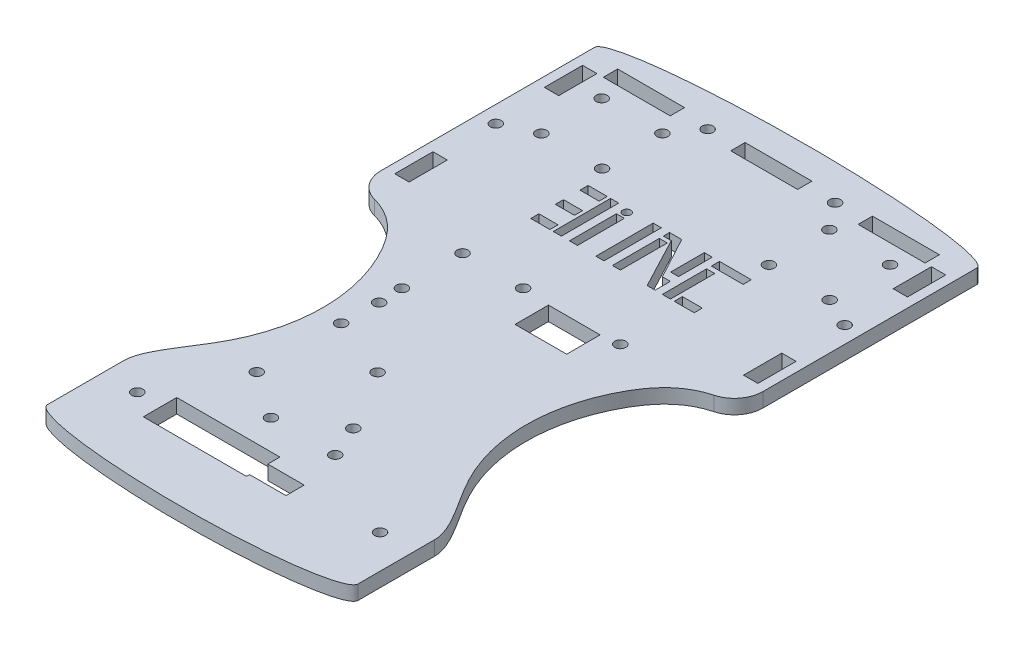
from build123d import *

# Parameters (mm, degrees)
SKETCH1_W           = 80
SKETCH1_H           = 100
BOSS_EXTRUDE1_DEPTH = 1.5
SKETCH2_R           = 1.15
SKETCH2_W           = 14
SKETCH2_H           = 3
CUT_EXTRUDE1_DEPTH  = 4
SKETCH3_R           = 1.15
SKETCH3_W           = 3
SKETCH3_H           = 8
CUT_EXTRUDE2_DEPTH  = 4
BOSS_EXTRUDE2_DEPTH = 3
SKETCH9_W           = 80
SKETCH9_H           = 6
BOSS_EXTRUDE3_DEPTH = 3
CUT_EXTRUDE4_DEPTH  = 4.0000001
BOSS_EXTRUDE4_DEPTH = 3
SKETCH12_R          = 1.143
CUT_EXTRUDE5_DEPTH  = 4.0000001
SKETCH13_R          = 1.15
CUT_EXTRUDE6_DEPTH  = 4.0000001
CUT_EXTRUDE7_DEPTH  = 4.0000001
FILLET1_R           = 6
SKETCH16_R          = 1.15
CUT_EXTRUDE8_DEPTH  = 4.0000001
SKETCH18_R          = 1.15
CUT_EXTRUDE10_DEPTH = 10
SKETCH20_W          = 1.668725188
SKETCH20_H          = 9.826400532
SKETCH20_W_2        = 1.7
SKETCH20_H_2        = 12
SKETCH20_W_3        = 1.668725187
SKETCH20_R          = 0.85
SKETCH20_W_4        = 4
SKETCH20_H_3        = 1.7
SKETCH20_W_5        = 1.660704434
SKETCH20_H_4        = 7.055688022
SKETCH20_H_5        = 9.27636253
SKETCH20_W_6        = 6.651137072
SKETCH20_W_7        = 4.178850885
CUT_EXTRUDE14_DEPTH = 10
SKETCH21_W          = 10.8
SKETCH21_H          = 7
SKETCH21_W_2        = 21.59
SKETCH21_H_2        = 0.65
CUT_EXTRUDE16_DEPTH = 10


with BuildPart() as part:
    # Sketch1 → Boss-Extrude1 (new body, symmetric)
    with BuildSketch(Plane(origin=(0, 0, 0), x_dir=(1, 0, 0), z_dir=(0, 1, 0))):
        Rectangle(SKETCH1_W, SKETCH1_H)
    extrude(amount=BOSS_EXTRUDE1_DEPTH, both=True)

    # Sketch2 → Cut-Extrude1 (cut, through all)
    with BuildSketch(Plane(origin=(0, 1.5, 0), x_dir=(1, 0, 0), z_dir=(0, 1, 0))):
        with Locations((-13.333333333, 47)):
            Circle(SKETCH2_R)
        with Locations((13.333333333, 47)):
            Circle(SKETCH2_R)
        with Locations((-26.666666667, 47)):
            Rectangle(SKETCH2_W, SKETCH2_H)
        with Locations((0, 47)):
            Rectangle(SKETCH2_W, SKETCH2_H)
        with Locations((26.666666667, 47)):
            Rectangle(SKETCH2_W, SKETCH2_H)
    extrude(amount=-CUT_EXTRUDE1_DEPTH, mode=Mode.SUBTRACT)

    # Sketch3 → Cut-Extrude2 (cut, through all)
    with BuildSketch(Plane(origin=(0, 1.5, 0), x_dir=(1, 0, 0), z_dir=(0, 1, 0))):
        with Locations((36.5, 25.841809836)):
            Circle(SKETCH3_R)
        with Locations((-36.5, 25.841809836)):
            Circle(SKETCH3_R)
        with Locations((-36.5, 41.5)):
            Rectangle(SKETCH3_W, SKETCH3_H)
        with Locations((-36.5, 10.183619672)):
            Rectangle(SKETCH3_W, SKETCH3_H)
        with Locations((36.5, 10.183619672)):
            Rectangle(SKETCH3_W, SKETCH3_H)
        with Locations((36.5, 41.5)):
            Rectangle(SKETCH3_W, SKETCH3_H)
    extrude(amount=-CUT_EXTRUDE2_DEPTH, mode=Mode.SUBTRACT)

    # Sketch5 → Boss-Extrude2 (add)
    with BuildSketch(Plane(origin=(0, 1.5, 0), x_dir=(1, 0, 0), z_dir=(0, 1, 0))):
        with BuildLine():
            Line((40, 50), (-40, 50))
            add(Edge.make_bspline(
                [(40, 50), (40, 54.5), (0, 54.5), (-40, 54.5), (-40, 50)],
                knots=[3.141592654, 3.141592654, 3.141592654, 4.71238898, 4.71238898, 6.283185307, 6.283185307, 6.283185307], degree=2, weights=[1, 0.707106781, 1, 0.707106781, 1]))
        make_face()
    extrude(amount=-BOSS_EXTRUDE2_DEPTH)

    # Sketch9 → Boss-Extrude3 (add)
    with BuildSketch(Plane(origin=(0, 1.5, 0), x_dir=(1, 0, 0), z_dir=(0, 1, 0))):
        with Locations((0, -53)):
            Rectangle(SKETCH9_W, SKETCH9_H)
    extrude(amount=-BOSS_EXTRUDE3_DEPTH)

    # Sketch7 → Cut-Extrude4 (cut, through all)
    with BuildSketch(Plane(origin=(0, 1.5, 0), x_dir=(1, 0, 0), z_dir=(0, 1, 0))):
        with BuildLine():
            Line((40, 0), (40, -56))
            Line((40, -56), (32.5, -56))
            add(Edge.make_bspline(
                [(40, 0), (32.098052341, 0), (20.551318803, -12.467121646), (19.339671373, -36.932831807), (32.5, -51.97801632), (32.5, -56)],
                knots=[0, 0, 0, 0, 0.268690214, 0.752947844, 1, 1, 1, 1], degree=3))
        make_face()
        with BuildLine():
            Line((-40, -56), (-32.5, -56))
            add(Edge.make_bspline(
                [(-40, 0), (-32.098052341, 0), (-20.551318803, -12.467121646), (-19.339671373, -36.932831807), (-32.5, -51.97801632), (-32.5, -56)],
                knots=[0, 0, 0, 0, 0.268690214, 0.752947844, 1, 1, 1, 1], degree=3))
            Line((-40, 0), (-40, -56))
        make_face()
    extrude(amount=-CUT_EXTRUDE4_DEPTH, mode=Mode.SUBTRACT)

    # Sketch11 → Boss-Extrude4 (add)
    with BuildSketch(Plane.XZ.offset(1.5)):
        with BuildLine():
            Line((32.5, 56), (32.5, 72))
            add(Edge.make_bspline(
                [(32.5, 72), (32.5, 76.5), (0, 76.5), (-32.5, 76.5), (-32.5, 72)],
                knots=[0, 0, 0, 1.570796327, 1.570796327, 3.141592654, 3.141592654, 3.141592654], degree=2, weights=[1, 0.707106781, 1, 0.707106781, 1]))
            Line((-32.5, 72), (-32.5, 56))
            Line((-32.5, 56), (32.5, 56))
        make_face()
    extrude(amount=-BOSS_EXTRUDE4_DEPTH)

    # Sketch12 → Cut-Extrude5 (cut, through all)
    with BuildSketch(Plane(origin=(0, 1.5, 0), x_dir=(1, 0, 0), z_dir=(0, 1, 0))):
        with Locations((-6.731, -51)):
            Circle(SKETCH12_R)
        with Locations((6.731, -51)):
            Circle(SKETCH12_R)
    extrude(amount=-CUT_EXTRUDE5_DEPTH, mode=Mode.SUBTRACT)

    # Sketch13 → Cut-Extrude6 (cut, through all)
    with BuildSketch(Plane(origin=(0, 1.5, 0), x_dir=(1, 0, 0), z_dir=(0, 1, 0))):
        with Locations((25.46, -60.356380328)):
            Circle(SKETCH13_R)
        with Locations((-25.34, -60.356380328)):
            Circle(SKETCH13_R)
    extrude(amount=-CUT_EXTRUDE6_DEPTH, mode=Mode.SUBTRACT)

    # Sketch15 → Cut-Extrude7 (cut, through all)
    with BuildSketch(Plane.XZ.offset(1.5)):
        Polygon((1.33, 57.181380328), (-20.26, 57.181380328), (-20.26, 63.531380328), (8.95, 63.531380328), (8.95, 59.721380328), (1.33, 59.721380328), align=None)
    extrude(amount=-CUT_EXTRUDE7_DEPTH, mode=Mode.SUBTRACT)

    # Fillet1
    fillet1_edges = [part.edges().sort_by_distance(p)[0] for p in [
        (40, 0, 0),
        (-40, 0, 0),
    ]]
    fillet(fillet1_edges, radius=FILLET1_R)

    # Sketch16 → Cut-Extrude8 (cut, through all)
    with BuildSketch(Plane.XZ.offset(1.5)):
        with Locations((-16.51, 13.826380328)):
            Circle(SKETCH16_R)
        with Locations((-16.296758127, 18.795764095)):
            Circle(SKETCH16_R)
        with Locations((-16.51, 26.526380328)):
            Circle(SKETCH16_R)
        with Locations((3.81, 44.306380328)):
            Circle(SKETCH16_R)
        with Locations((-3.81, 1.126380328)):
            Circle(SKETCH16_R)
        with Locations((16.51, 1.126380328)):
            Circle(SKETCH16_R)
        with Locations((-16.51, 1.126380328)):
            Circle(SKETCH16_R)
        with Locations((-3.81, 31.606380328)):
            Circle(SKETCH16_R)
        with Locations((-16.499422109, 44.194955565)):
            Circle(SKETCH16_R)
    extrude(amount=-CUT_EXTRUDE8_DEPTH, mode=Mode.SUBTRACT)

    # Sketch18 → Cut-Extrude10 (cut)
    with BuildSketch(Plane(origin=(0, 1.5, 0), x_dir=(1, 0, 0), z_dir=(0, 1, 0))):
        with Locations((-30.002504002, 41.5)):
            Circle(SKETCH18_R)
        with Locations((-29.948059122, 28.804836733)):
            Circle(SKETCH18_R)
        with Locations((-17.299282577, 41.502193702)):
            Circle(SKETCH18_R)
        with Locations((-17.244837697, 28.807030435)):
            Circle(SKETCH18_R)
        with Locations((17.622110636, 41.513247657)):
            Circle(SKETCH18_R)
        with Locations((17.676555516, 28.81808439)):
            Circle(SKETCH18_R)
        with Locations((30.325332061, 41.515441359)):
            Circle(SKETCH18_R)
        with Locations((30.379776941, 28.820278092)):
            Circle(SKETCH18_R)
    extrude(amount=-CUT_EXTRUDE10_DEPTH, mode=Mode.SUBTRACT)

    # Sketch20 → Cut-Extrude14 (cut)
    with BuildSketch(Plane(origin=(0, 1.5, 0), x_dir=(1, 0, 0), z_dir=(0, 1, 0))):
        with Locations((-6.722229591, 17.220281543)):
            Rectangle(SKETCH20_W, SKETCH20_H)
        with Locations((-1.165320265, 18.290869417)):
            Rectangle(SKETCH20_W_2, SKETCH20_H_2)
        with Locations((2.235394231, 17.248249793)):
            Rectangle(SKETCH20_W_3, SKETCH20_H)
        Polygon((10.347921496, 15.518932958), (10.347921496, 12.335049527), (8.679196309, 12.335049527), (3.069756825, 22.987791899), (1.401031638, 22.987791899), (1.401031638, 24.290869417), (3.951642669, 24.290869417), (8.679196309, 15.518932958), align=None)
        with Locations((-6.722229591, 23.455475764)):
            Circle(SKETCH20_R)
        with Locations((-13.65349282, 23.455475764)):
            Rectangle(SKETCH20_W_4, SKETCH20_H_3)
        with Locations((-10.103314063, 18.305475764)):
            Rectangle(SKETCH20_W_2, SKETCH20_H_2)
        with Locations((-13.654716874, 18.304596102)):
            Rectangle(SKETCH20_W_4, SKETCH20_H_3)
        with Locations((-13.658714089, 13.162576628)):
            Rectangle(SKETCH20_W_4, SKETCH20_H_3)
        with Locations((9.517569279, 20.763025406)):
            Rectangle(SKETCH20_W_5, SKETCH20_H_4)
        with Locations((12.713587641, 16.951250964)):
            Rectangle(SKETCH20_W_2, SKETCH20_H_5)
        with Locations((15.189156177, 23.437180525)):
            Rectangle(SKETCH20_W_6, SKETCH20_H_3)
        with Locations((16.451359952, 13.173437862)):
            Rectangle(SKETCH20_W_7, SKETCH20_H_3)
    extrude(amount=-CUT_EXTRUDE14_DEPTH, mode=Mode.SUBTRACT)

    # Sketch21 → Cut-Extrude16 (cut)
    with BuildSketch(Plane(origin=(0, 1.5, 0), x_dir=(1, 0, 0), z_dir=(0, 1, 0))):
        with Locations((7.291504624, -5.02816267)):
            Rectangle(SKETCH21_W, SKETCH21_H)
        with Locations((-9.465, -63.856380328)):
            Rectangle(SKETCH21_W_2, SKETCH21_H_2)
    extrude(amount=-CUT_EXTRUDE16_DEPTH, mode=Mode.SUBTRACT)


solid = part.part
